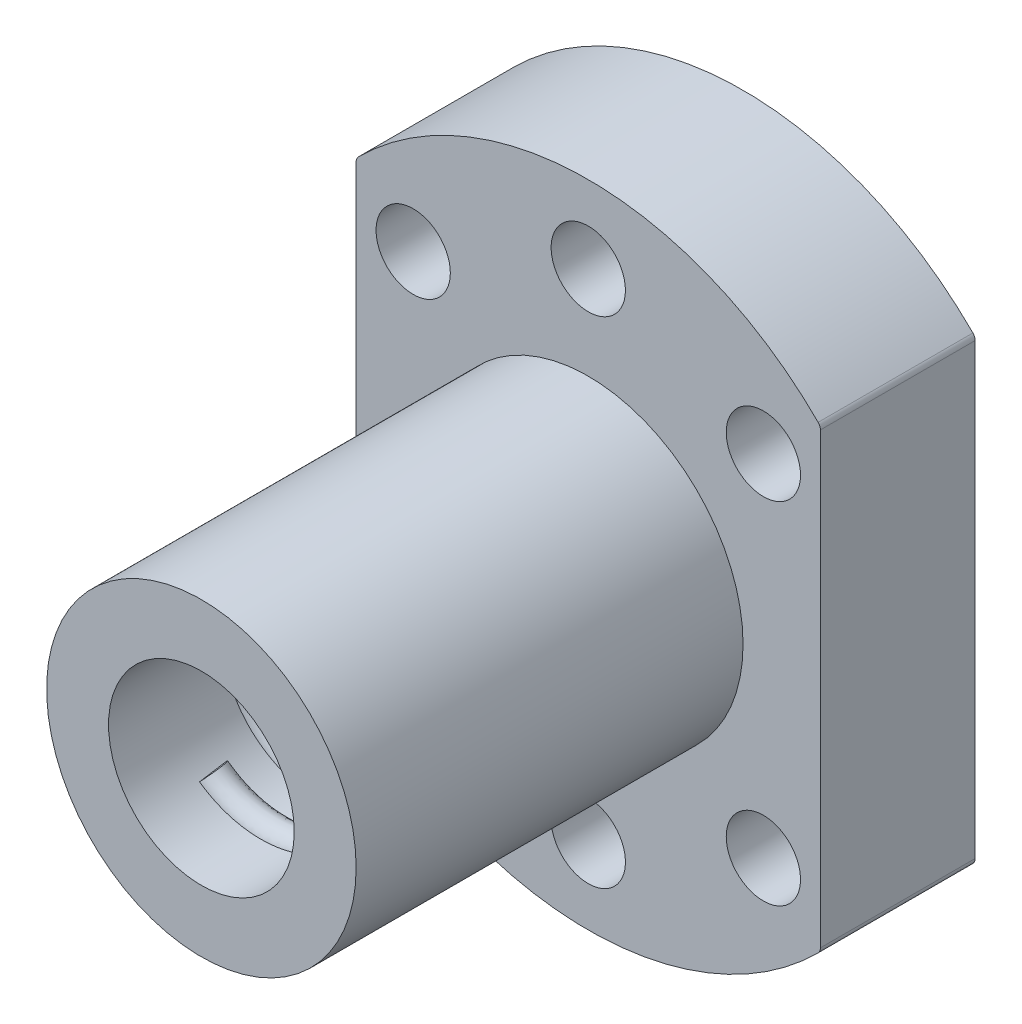
from build123d import *

# Parameters (mm, degrees)
SKETCH1_R           = 6
SKETCH1_R_2         = 2.4
BOSS_EXTRUDE1_DEPTH = 10
SKETCH2_R           = 10
SKETCH2_R_2         = 6
BOSS_EXTRUDE2_DEPTH = 25
SWEEP1_PITCH        = 4
SWEEP1_HEIGHT       = 20
SWEEP1_RADIUS       = 6
SWEEP1_START_ANGLE  = -135
SKETCH6_R           = 1
FILLET1_R           = 0.5


with BuildPart() as part:
    # Sketch1 → Boss-Extrude1 (new body)
    with BuildSketch(Plane.XY):
        with BuildLine():
            Line((-15, 14.696938457), (-15, -14.696938457))
            ThreePointArc((-15, -14.696938457), (0, -21), (15, -14.696938457))
            Line((15, -14.696938457), (15, 14.696938457))
            ThreePointArc((15, 14.696938457), (0, 21), (-15, 14.696938457))
        make_face()
        Circle(SKETCH1_R, mode=Mode.SUBTRACT)
        with Locations((0, 16)):
            Circle(SKETCH1_R_2, mode=Mode.SUBTRACT)
        with Locations((-11.313708499, 11.313708499)):
            Circle(SKETCH1_R_2, mode=Mode.SUBTRACT)
        with Locations((11.313708499, 11.313708499)):
            Circle(SKETCH1_R_2, mode=Mode.SUBTRACT)
        with Locations((11.313708499, -11.313708499)):
            Circle(SKETCH1_R_2, mode=Mode.SUBTRACT)
        with Locations((0, -16)):
            Circle(SKETCH1_R_2, mode=Mode.SUBTRACT)
        with Locations((-11.313708499, -11.313708499)):
            Circle(SKETCH1_R_2, mode=Mode.SUBTRACT)
    extrude(amount=BOSS_EXTRUDE1_DEPTH)

    # Sketch2 → Boss-Extrude2 (add)
    with BuildSketch(Plane.XY.offset(10)):
        Circle(SKETCH2_R)
        Circle(SKETCH2_R_2, mode=Mode.SUBTRACT)
    extrude(amount=BOSS_EXTRUDE2_DEPTH)

    # Sweep1: sweep along a helix
    with BuildLine() as sweep1_path:
        add(Helix(SWEEP1_PITCH, SWEEP1_HEIGHT, SWEEP1_RADIUS, center=(0, 0, 10), direction=(0, 0, 1), lefthand=True, mode=Mode.PRIVATE).rotate(Axis((0, 0, 10), (0, 0, 1)), SWEEP1_START_ANGLE))
    # Sketch6 → Sweep1 (sweep)
    with BuildSketch(Plane(origin=(-4.242640687, -4.242640687, 10), x_dir=(-0.074607572, 0.074607572, -0.994418132), z_dir=(0.703159804, -0.703159804, -0.105511041))):
        with Locations((-1.935e-06, -0.300000373)):
            Circle(SKETCH6_R)
    sweep(path=sweep1_path.line, is_frenet=True)

    # Fillet1
    fillet1_edges = [part.edges().sort_by_distance(p)[0] for p in [
        (15, 14.696938457, 5),
        (15, -14.696938457, 5),
        (-15, -14.696938457, 5),
        (-15, 14.696938457, 5),
    ]]
    fillet(fillet1_edges, radius=FILLET1_R)


solid = part.part
